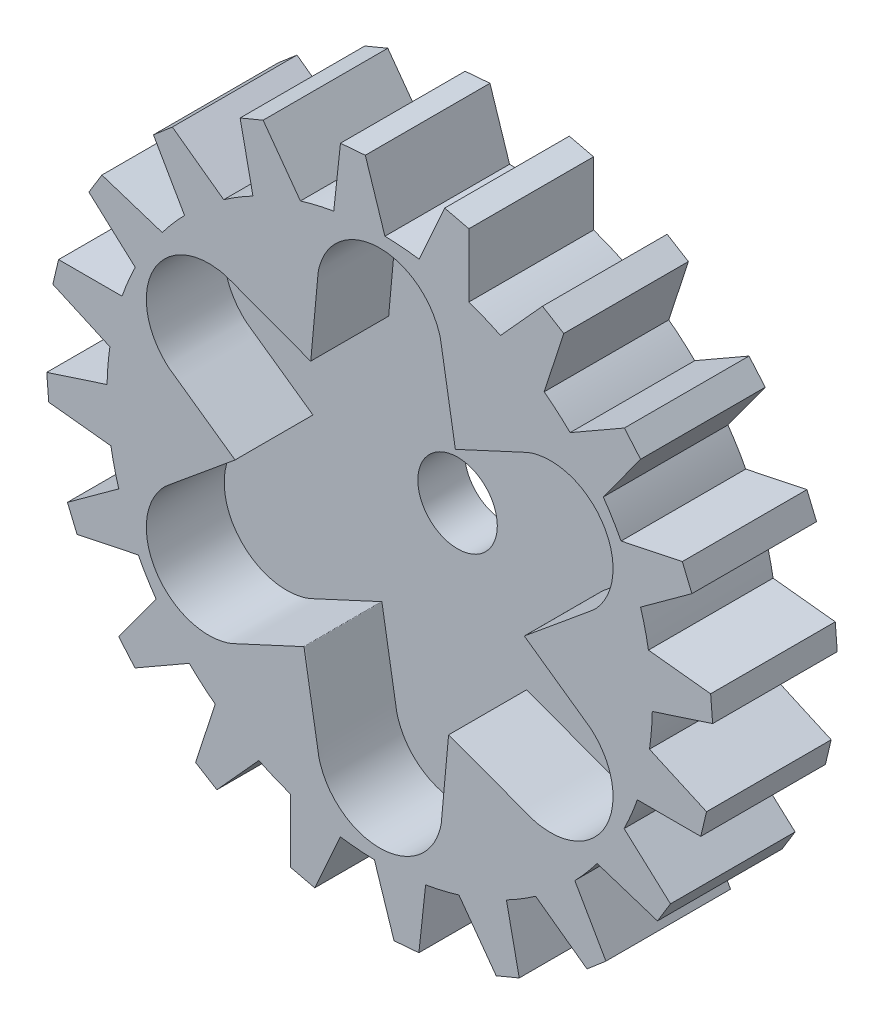
from build123d import *

# Parameters (mm, degrees)
SKETCH1_R               = 17.5
BOSS_EXTRUDE1_DEPTH     = 8
SKETCH3_R               = 2.55
CUT_EXTRUDE1_DEPTH      = 1
CUT_EXTRUDE1_DEPTH_BACK = 9
SKETCH4_R               = 2.55
CUT_EXTRUDE2_DEPTH      = 5


with BuildPart() as part:
    # Sketch1 → Boss-Extrude1 (new body)
    with BuildSketch(Plane.XY):
        with BuildLine():
            Line((5.72690895, 20.608274926), (4.170382138, 20.978712886))
            Line((4.170382138, 20.978712886), (2.52690895, 17.31660276))
            ThreePointArc((2.52690895, 17.31660276), (4.145305381, 17.001954102), (5.72690895, 16.536399665))
            Line((5.72690895, 16.536399665), (5.72690895, 20.608274926))
        make_face()
        with BuildLine():
            Line((10.44904791, 18.66322264), (7.754357761, 15.688210086))
            ThreePointArc((7.754357761, 15.688210086), (9.19631245, 14.888849429), (10.556642598, 13.957338466))
            Line((10.556642598, 13.957338466), (11.814921252, 17.829921967))
            Line((11.814921252, 17.829921967), (10.44904791, 18.66322264))
        make_face()
        with BuildLine():
            Line((15.704888069, 14.520846128), (12.222756006, 12.524146103))
            ThreePointArc((12.222756006, 12.524146103), (13.347120382, 11.318320437), (14.353018515, 10.012035732))
            Line((14.353018515, 10.012035732), (16.746406743, 13.306252017))
            Line((16.746406743, 13.306252017), (15.704888069, 14.520846128))
        make_face()
        with BuildLine():
            Line((19.423424362, 8.957068024), (15.494705733, 8.134131438))
            ThreePointArc((15.494705733, 8.134131438), (16.191419176, 6.639875381), (16.744420977, 5.086685183))
            Line((16.744420977, 5.086685183), (20.038637262, 7.480073411))
            Line((20.038637262, 7.480073411), (19.423424362, 8.957068024))
        make_face()
        with BuildLine():
            Line((21.240660548, 2.516509694), (17.249925704, 2.947891315))
            ThreePointArc((17.249925704, 2.947891315), (17.437369352, 1.4792397), (17.5, 0))
            ThreePointArc((17.5, 0), (17.499190693, -0.16830056), (17.496762848, -0.336585553))
            Line((17.496762848, -0.336585553), (21.369346349, 0.921693101))
            Line((21.369346349, 0.921693101), (21.240660548, 2.516509694))
        make_face()
        with BuildLine():
            Line((20.978712886, -4.170382138), (17.31660276, -2.52690895))
            ThreePointArc((17.31660276, -2.52690895), (17.001954102, -4.145305381), (16.536399665, -5.72690895))
            Line((16.536399665, -5.72690895), (20.608274926, -5.72690895))
            Line((20.608274926, -5.72690895), (20.978712886, -4.170382138))
        make_face()
        with BuildLine():
            Line((18.66322264, -10.44904791), (15.688210086, -7.754357761))
            ThreePointArc((15.688210086, -7.754357761), (14.888849429, -9.19631245), (13.957338466, -10.556642598))
            Line((13.957338466, -10.556642598), (17.829921967, -11.814921252))
            Line((17.829921967, -11.814921252), (18.66322264, -10.44904791))
        make_face()
        with BuildLine():
            Line((14.520846128, -15.704888069), (12.524146103, -12.222756006))
            ThreePointArc((12.524146103, -12.222756006), (11.318320437, -13.347120382), (10.012035732, -14.353018515))
            Line((10.012035732, -14.353018515), (13.306252017, -16.746406743))
            Line((13.306252017, -16.746406743), (14.520846128, -15.704888069))
        make_face()
        with BuildLine():
            Line((8.957068024, -19.423424362), (8.134131438, -15.494705733))
            ThreePointArc((8.134131438, -15.494705733), (6.639875381, -16.191419176), (5.086685183, -16.744420977))
            Line((5.086685183, -16.744420977), (7.480073411, -20.038637262))
            Line((7.480073411, -20.038637262), (8.957068024, -19.423424362))
        make_face()
        with BuildLine():
            Line((2.516509694, -21.240660548), (2.947891315, -17.249925704))
            ThreePointArc((2.947891315, -17.249925704), (1.311473061, -17.450789048), (-0.336585553, -17.496762848))
            Line((-0.336585553, -17.496762848), (0.921693101, -21.369346349))
            Line((0.921693101, -21.369346349), (2.516509694, -21.240660548))
        make_face()
        with BuildLine():
            ThreePointArc((-2.52690895, -17.31660276), (-4.145305381, -17.001954102), (-5.72690895, -16.536399665))
            Line((-5.72690895, -16.536399665), (-5.72690895, -20.608274926))
            Line((-5.72690895, -20.608274926), (-4.170382138, -20.978712886))
            Line((-4.170382138, -20.978712886), (-2.52690895, -17.31660276))
        make_face()
        with BuildLine():
            ThreePointArc((-7.754357761, -15.688210086), (-9.19631245, -14.888849429), (-10.556642598, -13.957338466))
            Line((-10.556642598, -13.957338466), (-11.814921252, -17.829921967))
            Line((-11.814921252, -17.829921967), (-10.44904791, -18.66322264))
            Line((-10.44904791, -18.66322264), (-7.754357761, -15.688210086))
        make_face()
        with BuildLine():
            ThreePointArc((-12.222756006, -12.524146103), (-13.347120382, -11.318320437), (-14.353018515, -10.012035732))
            Line((-14.353018515, -10.012035732), (-16.746406743, -13.306252017))
            Line((-16.746406743, -13.306252017), (-15.704888069, -14.520846128))
            Line((-15.704888069, -14.520846128), (-12.222756006, -12.524146103))
        make_face()
        with BuildLine():
            ThreePointArc((-15.494705733, -8.134131438), (-16.191419176, -6.639875381), (-16.744420977, -5.086685183))
            Line((-16.744420977, -5.086685183), (-20.038637262, -7.480073411))
            Line((-20.038637262, -7.480073411), (-19.423424362, -8.957068024))
            Line((-19.423424362, -8.957068024), (-15.494705733, -8.134131438))
        make_face()
        with BuildLine():
            ThreePointArc((-17.249925704, -2.947891315), (-17.450789048, -1.311473061), (-17.496762848, 0.336585553))
            Line((-17.496762848, 0.336585553), (-21.369346349, -0.921693101))
            Line((-21.369346349, -0.921693101), (-21.240660548, -2.516509694))
            Line((-21.240660548, -2.516509694), (-17.249925704, -2.947891315))
        make_face()
        with BuildLine():
            ThreePointArc((-17.31660276, 2.52690895), (-17.001954102, 4.145305381), (-16.536399665, 5.72690895))
            Line((-16.536399665, 5.72690895), (-20.608274926, 5.72690895))
            Line((-20.608274926, 5.72690895), (-20.978712886, 4.170382138))
            Line((-20.978712886, 4.170382138), (-17.31660276, 2.52690895))
        make_face()
        with BuildLine():
            ThreePointArc((-15.688210086, 7.754357761), (-14.888849429, 9.19631245), (-13.957338466, 10.556642598))
            Line((-13.957338466, 10.556642598), (-17.829921967, 11.814921252))
            Line((-17.829921967, 11.814921252), (-18.66322264, 10.44904791))
            Line((-18.66322264, 10.44904791), (-15.688210086, 7.754357761))
        make_face()
        with BuildLine():
            ThreePointArc((-12.524146103, 12.222756006), (-11.318320437, 13.347120382), (-10.012035732, 14.353018515))
            Line((-10.012035732, 14.353018515), (-13.306252017, 16.746406743))
            Line((-13.306252017, 16.746406743), (-14.520846128, 15.704888069))
            Line((-14.520846128, 15.704888069), (-12.524146103, 12.222756006))
        make_face()
        with BuildLine():
            ThreePointArc((-8.134131438, 15.494705733), (-6.639875381, 16.191419176), (-5.086685183, 16.744420977))
            Line((-5.086685183, 16.744420977), (-7.480073411, 20.038637262))
            Line((-7.480073411, 20.038637262), (-8.957068024, 19.423424362))
            Line((-8.957068024, 19.423424362), (-8.134131438, 15.494705733))
        make_face()
        with BuildLine():
            ThreePointArc((-2.947891315, 17.249925704), (-1.311473061, 17.450789048), (0.336585553, 17.496762848))
            Line((0.336585553, 17.496762848), (-0.921693101, 21.369346349))
            Line((-0.921693101, 21.369346349), (-2.516509694, 21.240660548))
            Line((-2.516509694, 21.240660548), (-2.947891315, 17.249925704))
        make_face()
        Circle(SKETCH1_R)
    extrude(amount=BOSS_EXTRUDE1_DEPTH)

    # Sketch3 → Cut-Extrude1 (cut, two sides)
    with BuildSketch(Plane.XY.offset(8)) as cut_extrude1_sk:
        Circle(SKETCH3_R)
    extrude(amount=CUT_EXTRUDE1_DEPTH, mode=Mode.SUBTRACT)
    extrude(cut_extrude1_sk.sketch, amount=-CUT_EXTRUDE1_DEPTH_BACK, mode=Mode.SUBTRACT)

    # Sketch4 → Cut-Extrude2 (cut)
    with BuildSketch(Plane.XY.offset(8)):
        with BuildLine():
            add(Edge.make_bspline(
                [(8.421463214, -9.653914634), (7.095246797, -9.159414871), (5.76903038, -8.664915107), (4.442813963, -8.170415344), (4.44031202, -8.169482457), (4.435308133, -8.167616682), (4.422273222, -8.173641272), (4.421793577, -8.1789601), (4.421553755, -8.181619515), (4.312262947, -9.393556075), (4.20297214, -10.605492635), (4.093681332, -11.817429195), (4.08147609, -11.952774332), (4.057065605, -12.223464605), (4.020449879, -12.629500014), (3.996039394, -12.900190287), (3.983834152, -13.035535424), (3.971410991, -13.173297088), (3.946564668, -13.448820417), (3.829770692, -13.85545638), (3.734626549, -14.11561776), (3.680452914, -14.24288845), (2.155420805, -17.825662393), (-1.735279276, -17.982011173), (-3.542879046, -14.533159896), (-3.607816081, -14.409261798), (-3.72469162, -14.154652858), (-3.874917089, -13.75383399), (-3.921339059, -13.477944104), (-3.944550044, -13.33999916), (-3.967356007, -13.204461298), (-4.012967933, -12.933385573), (-4.081385823, -12.526771985), (-4.126997749, -12.25569626), (-4.149803712, -12.120158397), (-4.384662563, -10.724371408), (-4.619521414, -9.328584418), (-4.854380266, -7.932797428), (-4.854823333, -7.930164238), (-4.855709468, -7.924897858), (-4.867444372, -7.916621589), (-4.872290435, -7.918865618), (-4.874713466, -7.919987633), (-5.978926719, -8.431307297), (-7.083139972, -8.942626962), (-8.187353225, -9.453946626), (-8.310668172, -9.511049145), (-8.557298067, -9.625254181), (-8.92724291, -9.796561737), (-9.173872805, -9.910766774), (-9.297187753, -9.967869292), (-9.422704435, -10.025991351), (-9.673737799, -10.142235469), (-10.08429186, -10.2444069), (-10.357170296, -10.292090345), (-10.494476764, -10.308809946), (-14.359766069, -10.77948037), (-16.440518125, -7.488209651), (-14.35752519, -4.198356691), (-14.282694807, -4.080170521), (-14.120634767, -3.851648864), (-13.848628179, -3.521140358), (-13.632911514, -3.34299281), (-13.525053181, -3.253919036), (-13.419076931, -3.166399561), (-13.20712443, -2.991360612), (-12.889195678, -2.728802187), (-12.677243177, -2.553763238), (-12.571266926, -2.466243763), (-11.47990936, -1.564956537), (-10.388551795, -0.663669311), (-9.297194229, 0.237617915), (-9.295135353, 0.239318218), (-9.291017602, 0.242718824), (-9.289717594, 0.257019683), (-9.294084012, 0.260094482), (-9.296267221, 0.261631882), (-10.291189666, 0.962248777), (-11.286112111, 1.662865673), (-12.281034557, 2.363482569), (-12.392144262, 2.441725187), (-12.614363673, 2.598210423), (-12.947692789, 2.832938278), (-13.169912199, 2.989423514), (-13.281021905, 3.067666132), (-13.394115425, 3.147305737), (-13.620302466, 3.306584949), (-13.914062552, 3.61104948), (-14.091796845, 3.823527415), (-14.174929677, 3.934078504), (-16.515186874, 7.046182024), (-14.705238849, 10.493801522), (-10.814646144, 10.334803205), (-10.674878726, 10.329091277), (-10.395943146, 10.303003994), (-9.97371109, 10.232693631), (-9.711572455, 10.134951294), (-9.580503137, 10.086080125), (-9.451720924, 10.038061737), (-9.194156496, 9.942024961), (-8.807809855, 9.797969798), (-8.550245428, 9.701933022), (-8.421463214, 9.653914634), (-7.095246797, 9.159414871), (-5.76903038, 8.664915107), (-4.442813963, 8.170415344), (-4.44031202, 8.169482457), (-4.435308133, 8.167616682), (-4.422273222, 8.173641272), (-4.421793577, 8.1789601), (-4.421553755, 8.181619515), (-4.312262947, 9.393556075), (-4.20297214, 10.605492635), (-4.093681332, 11.817429195), (-4.08147609, 11.952774332), (-4.057065605, 12.223464605), (-4.020449879, 12.629500014), (-3.996039394, 12.900190287), (-3.983834152, 13.035535424), (-3.971410991, 13.173297088), (-3.946564668, 13.448820417), (-3.829770692, 13.85545638), (-3.734626549, 14.11561776), (-3.680452914, 14.24288845), (-2.155420805, 17.825662393), (1.735279276, 17.982011173), (3.542879046, 14.533159896), (3.607816081, 14.409261798), (3.72469162, 14.154652858), (3.874917089, 13.75383399), (3.921339059, 13.477944104), (3.944550044, 13.33999916), (3.967356007, 13.204461298), (4.012967933, 12.933385573), (4.081385823, 12.526771985), (4.126997749, 12.25569626), (4.149803712, 12.120158397), (4.384662563, 10.724371408), (4.619521414, 9.328584418), (4.854380266, 7.932797428), (4.854823333, 7.930164238), (4.855709468, 7.924897858), (4.867444372, 7.916621589), (4.872290435, 7.918865618), (4.874713466, 7.919987633), (5.978926719, 8.431307297), (7.083139972, 8.942626962), (8.187353225, 9.453946626), (8.310668172, 9.511049145), (8.557298067, 9.625254181), (8.92724291, 9.796561737), (9.173872805, 9.910766774), (9.297187753, 9.967869292), (9.422704435, 10.025991351), (9.673737799, 10.142235469), (10.08429186, 10.2444069), (10.357170296, 10.292090345), (10.494476764, 10.308809946), (14.359766069, 10.77948037), (16.440518125, 7.488209651), (14.35752519, 4.198356691), (14.282694807, 4.080170521), (14.120634767, 3.851648864), (13.848628179, 3.521140358), (13.632911514, 3.34299281), (13.525053181, 3.253919036), (13.419076931, 3.166399561), (13.20712443, 2.991360612), (12.889195678, 2.728802187), (12.677243177, 2.553763238), (12.571266926, 2.466243763), (11.47990936, 1.564956537), (10.388551795, 0.663669311), (9.297194229, -0.237617915), (9.295135353, -0.239318218), (9.291017602, -0.242718824), (9.289717594, -0.257019683), (9.294084012, -0.260094482), (9.296267221, -0.261631882), (10.291189666, -0.962248777), (11.286112111, -1.662865673), (12.281034557, -2.363482569), (12.392144262, -2.441725187), (12.614363673, -2.598210423), (12.947692789, -2.832938278), (13.169912199, -2.989423514), (13.281021905, -3.067666132), (13.394115425, -3.147305737), (13.620302466, -3.306584949), (13.914062552, -3.61104948), (14.091796845, -3.823527415), (14.174929677, -3.934078504), (16.515186874, -7.046182024), (14.705238849, -10.493801522), (10.814646144, -10.334803205), (10.674878726, -10.329091277), (10.395943146, -10.303003994), (9.97371109, -10.232693631), (9.711572455, -10.134951294), (9.580503137, -10.086080125), (9.451720924, -10.038061737), (9.194156496, -9.942024961), (8.807809855, -9.797969798), (8.550245428, -9.701933022), (8.421463214, -9.653914634)],
                knots=[0, 0, 0, 0, 0.035184891, 0.035184891, 0.035184891, 0.035251268, 0.035317645, 0.035384023, 0.035384023, 0.035384023, 0.065633172, 0.065633172, 0.065633172, 0.069011299, 0.072389426, 0.075767552, 0.075767552, 0.075767552, 0.079205994, 0.082644436, 0.086082878, 0.086082878, 0.086082878, 0.145984866, 0.145984866, 0.145984866, 0.149462172, 0.152939477, 0.156416783, 0.156416783, 0.156416783, 0.159833411, 0.163250039, 0.166666667, 0.166666667, 0.166666667, 0.201851558, 0.201851558, 0.201851558, 0.201917935, 0.201984312, 0.202050689, 0.202050689, 0.202050689, 0.232299839, 0.232299839, 0.232299839, 0.235677966, 0.239056092, 0.242434219, 0.242434219, 0.242434219, 0.245872661, 0.249311103, 0.252749544, 0.252749544, 0.252749544, 0.312651533, 0.312651533, 0.312651533, 0.316128838, 0.319606144, 0.323083449, 0.323083449, 0.323083449, 0.326500077, 0.329916705, 0.333333333, 0.333333333, 0.333333333, 0.368518224, 0.368518224, 0.368518224, 0.368584602, 0.368650979, 0.368717356, 0.368717356, 0.368717356, 0.398966506, 0.398966506, 0.398966506, 0.402344632, 0.405722759, 0.409100886, 0.409100886, 0.409100886, 0.412539328, 0.415977769, 0.419416211, 0.419416211, 0.419416211, 0.479318199, 0.479318199, 0.479318199, 0.482795505, 0.48627281, 0.489750116, 0.489750116, 0.489750116, 0.493166744, 0.496583372, 0.5, 0.5, 0.5, 0.535184891, 0.535184891, 0.535184891, 0.535251268, 0.535317645, 0.535384023, 0.535384023, 0.535384023, 0.565633172, 0.565633172, 0.565633172, 0.569011299, 0.572389426, 0.575767552, 0.575767552, 0.575767552, 0.579205994, 0.582644436, 0.586082878, 0.586082878, 0.586082878, 0.645984866, 0.645984866, 0.645984866, 0.649462172, 0.652939477, 0.656416783, 0.656416783, 0.656416783, 0.659833411, 0.663250039, 0.666666667, 0.666666667, 0.666666667, 0.701851558, 0.701851558, 0.701851558, 0.701917935, 0.701984312, 0.702050689, 0.702050689, 0.702050689, 0.732299839, 0.732299839, 0.732299839, 0.735677966, 0.739056092, 0.742434219, 0.742434219, 0.742434219, 0.745872661, 0.749311103, 0.752749544, 0.752749544, 0.752749544, 0.812651533, 0.812651533, 0.812651533, 0.816128838, 0.819606144, 0.823083449, 0.823083449, 0.823083449, 0.826500077, 0.829916705, 0.833333333, 0.833333333, 0.833333333, 0.868518224, 0.868518224, 0.868518224, 0.868584602, 0.868650979, 0.868717356, 0.868717356, 0.868717356, 0.898966506, 0.898966506, 0.898966506, 0.902344632, 0.905722759, 0.909100886, 0.909100886, 0.909100886, 0.912539328, 0.915977769, 0.919416211, 0.919416211, 0.919416211, 0.979318199, 0.979318199, 0.979318199, 0.982795505, 0.98627281, 0.989750116, 0.989750116, 0.989750116, 0.993166744, 0.996583372, 1, 1, 1, 1], degree=3, weights=[1, 1, 1, 1, 1, 1, 1, 1, 1, 1, 1, 1, 1, 1, 1, 1, 1, 1, 1, 1, 1, 1, 0.618854517, 0.618854517, 1, 1, 1, 1, 1, 1, 1, 1, 1, 1, 1, 1, 1, 1, 1, 1, 1, 1, 1, 1, 1, 1, 1, 1, 1, 1, 1, 1, 1, 1, 1, 1, 0.618854517, 0.618854517, 1, 1, 1, 1, 1, 1, 1, 1, 1, 1, 1, 1, 1, 1, 1, 1, 1, 1, 1, 1, 1, 1, 1, 1, 1, 1, 1, 1, 1, 1, 1, 1, 0.618854517, 0.618854517, 1, 1, 1, 1, 1, 1, 1, 1, 1, 1, 1, 1, 1, 1, 1, 1, 1, 1, 1, 1, 1, 1, 1, 1, 1, 1, 1, 1, 1, 1, 1, 1, 0.618854517, 0.618854517, 1, 1, 1, 1, 1, 1, 1, 1, 1, 1, 1, 1, 1, 1, 1, 1, 1, 1, 1, 1, 1, 1, 1, 1, 1, 1, 1, 1, 1, 1, 1, 1, 0.618854517, 0.618854517, 1, 1, 1, 1, 1, 1, 1, 1, 1, 1, 1, 1, 1, 1, 1, 1, 1, 1, 1, 1, 1, 1, 1, 1, 1, 1, 1, 1, 1, 1, 1, 1, 0.618854517, 0.618854517, 1, 1, 1, 1, 1, 1, 1, 1, 1, 1, 1]))
        make_face()
        Circle(SKETCH4_R, mode=Mode.SUBTRACT)
    extrude(amount=-CUT_EXTRUDE2_DEPTH, mode=Mode.SUBTRACT)


solid = part.part
